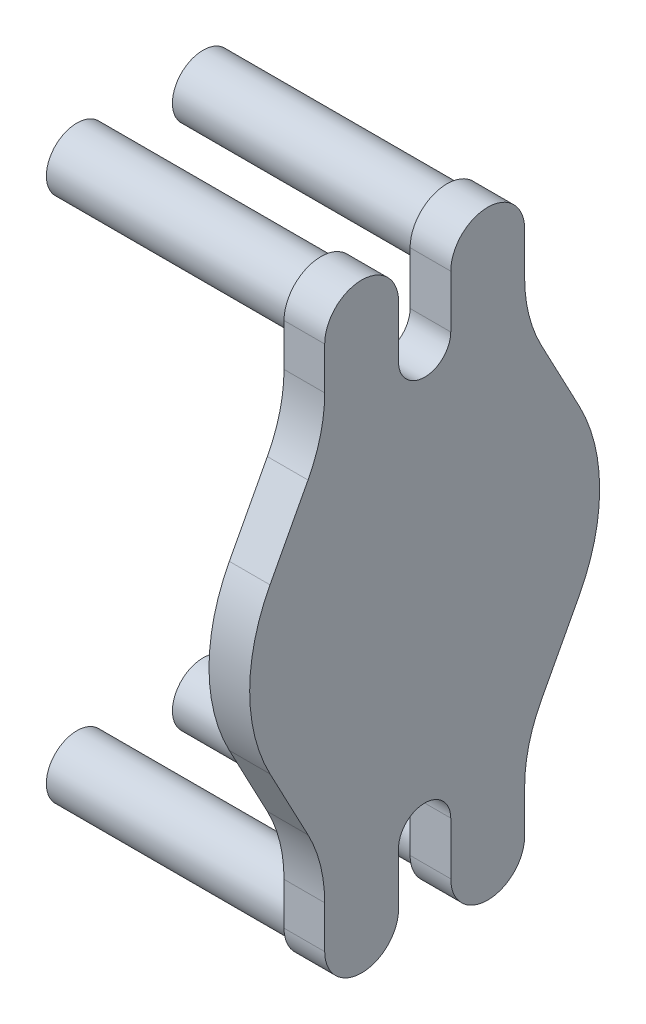
from build123d import *

# Parameters (mm, degrees)
SKETCH1_W           = 17.145
SKETCH1_H           = 18.25
SKETCH2_R           = 3.71475
CUT_EXTRUDE1_DEPTH  = 8.5725
SKETCH3_R           = 18.25
BOSS_EXTRUDE1_DEPTH = 8.5
SKETCH4_R           = 6.4
SKETCH4_R_2         = 4.75
BOSS_EXTRUDE2_DEPTH = 51
SKETCH5_R           = 18.25
CUT_EXTRUDE2_DEPTH  = 22.15


with BuildPart() as part:
    # Sketch1 → Revolve1 (revolve)
    with BuildSketch(Plane.XY):
        with Locations((16.8275, 9.125)):
            Rectangle(SKETCH1_W, SKETCH1_H)
    revolve(axis=Axis((8.255, 0, 0), (1, 0, 0)))

    # Sketch2 → Cut-Extrude1 (cut)
    with BuildSketch(Plane.ZY.offset(-8.255)):
        Circle(SKETCH2_R)
    extrude(amount=-CUT_EXTRUDE1_DEPTH, mode=Mode.SUBTRACT)


with BuildPart() as body_2:
    # Sketch3 → Boss-Extrude1 (new body)
    with BuildSketch(Plane(origin=(25.4, 0, 0), x_dir=(0, 0, -1), z_dir=(1, 0, 0))):
        with BuildLine():
            Line((-24.382347836, 32.115154563), (-32.324530318, 17.115154563))
            ThreePointArc((-32.324530318, 17.115154563), (-36.576, 0), (-32.324530318, -17.115154563))
            Line((-32.324530318, -17.115154563), (-24.382347836, -32.115154563))
            ThreePointArc((-24.382347836, -32.115154563), (-21.780072988, -38.920854003), (-20.89525, -46.153175037))
            Line((-20.89525, -46.153175037), (-20.89525, -55))
            ThreePointArc((-20.89525, -55), (-13.175, -62.72025), (-5.45475, -55))
            Line((-5.45475, -55), (-5.45475, -44))
            ThreePointArc((-5.45475, -44), (0, -38.54525), (5.45475, -44))
            Line((5.45475, -44), (5.45475, -55))
            ThreePointArc((5.45475, -55), (13.175, -62.72025), (20.89525, -55))
            Line((20.89525, -55), (20.89525, -46.153175037))
            ThreePointArc((20.89525, -46.153175037), (21.780072988, -38.920854003), (24.382347836, -32.115154563))
            Line((24.382347836, -32.115154563), (32.324530318, -17.115154563))
            ThreePointArc((32.324530318, -17.115154563), (36.576, 0), (32.324530318, 17.115154563))
            Line((32.324530318, 17.115154563), (24.382347836, 32.115154563))
            ThreePointArc((24.382347836, 32.115154563), (21.780072988, 38.920854003), (20.89525, 46.153175037))
            Line((20.89525, 46.153175037), (20.89525, 55))
            ThreePointArc((20.89525, 55), (13.175, 62.72025), (5.45475, 55))
            Line((5.45475, 55), (5.45475, 44))
            ThreePointArc((5.45475, 44), (0, 38.54525), (-5.45475, 44))
            Line((-5.45475, 44), (-5.45475, 55))
            ThreePointArc((-5.45475, 55), (-13.175, 62.72025), (-20.89525, 55))
            Line((-20.89525, 55), (-20.89525, 46.153175037))
            ThreePointArc((-20.89525, 46.153175037), (-21.780072988, 38.920854003), (-24.382347836, 32.115154563))
        make_face()
        Circle(SKETCH3_R, mode=Mode.SUBTRACT)
        Circle(SKETCH3_R)
    extrude(amount=BOSS_EXTRUDE1_DEPTH)

    # Sketch4 → Boss-Extrude2 (add)
    with BuildSketch(Plane.ZY.offset(-25.4)):
        with Locations((-13.175, 55)):
            Circle(SKETCH4_R)
        with Locations((-13.175, 55)):
            Circle(SKETCH4_R_2, mode=Mode.SUBTRACT)
        with Locations((13.175, 55)):
            Circle(SKETCH4_R)
        with Locations((13.175, 55)):
            Circle(SKETCH4_R_2, mode=Mode.SUBTRACT)
        with Locations((13.175, -55)):
            Circle(SKETCH4_R)
        with Locations((13.175, -55)):
            Circle(SKETCH4_R_2, mode=Mode.SUBTRACT)
        with Locations((-13.175, -55)):
            Circle(SKETCH4_R)
        with Locations((-13.175, -55)):
            Circle(SKETCH4_R_2, mode=Mode.SUBTRACT)
    extrude(amount=BOSS_EXTRUDE2_DEPTH)


with BuildPart() as cut_extrude2_tool:
    # Sketch5 → Cut-Extrude2 (new body)
    with BuildSketch(Plane.ZY.offset(-8.255)):
        Circle(SKETCH5_R)
    extrude(amount=-CUT_EXTRUDE2_DEPTH)


with BuildPart() as part_1:
    add(part.part)

    # Cut-Extrude2: cut by cut_extrude2_tool
    add(cut_extrude2_tool.part, mode=Mode.SUBTRACT)


with BuildPart() as body_2_1:
    add(body_2.part)

    # Cut-Extrude2: cut by cut_extrude2_tool
    add(cut_extrude2_tool.part, mode=Mode.SUBTRACT)


solid = body_2_1.part
